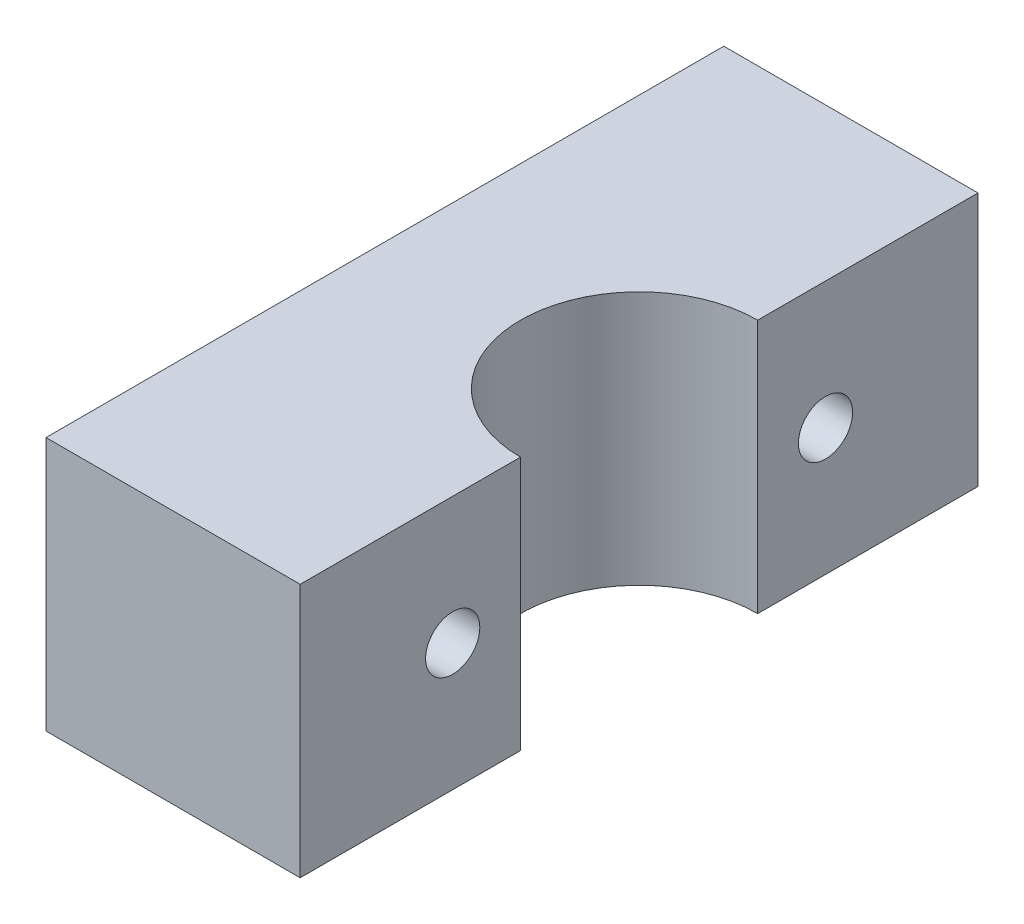
from build123d import *

# Parameters (mm, degrees)
BOSS_EXTRUDE1_DEPTH = 15
CUT_EXTRUDE2_REACH  = 17
SKETCH4_R           = 1.6


with BuildPart() as part:
    # Sketch1 → Boss-Extrude1 (new body)
    with BuildSketch(Plane(origin=(0, 0, 0), x_dir=(1, 0, 0), z_dir=(0, 1, 0))):
        with BuildLine():
            Line((7.5, 20), (7.5, 7))
            ThreePointArc((7.5, 7), (0.5, 0), (7.5, -7))
            Line((7.5, -7), (7.5, -20))
            Line((7.5, -20), (-7.5, -20))
            Line((-7.5, -20), (-7.5, 20))
            Line((-7.5, 20), (7.5, 20))
        make_face()
    extrude(amount=BOSS_EXTRUDE1_DEPTH)

    # Sketch4 → Cut-Extrude2 (cut, up to next)
    with BuildSketch(Plane(origin=(7.5, 0, 0), x_dir=(0, 0, -1), z_dir=(1, 0, 0)), mode=Mode.PRIVATE) as cut_extrude2_sk1:
        with Locations((11, 7.5)):
            Circle(SKETCH4_R)
    cut_extrude2_tool1 = extrude(cut_extrude2_sk1.sketch, amount=-CUT_EXTRUDE2_REACH, mode=Mode.PRIVATE) & part.part
    add(cut_extrude2_tool1.solids().sort_by_distance((7.5, 7.5, -11))[0], mode=Mode.SUBTRACT)
    # Sketch4 → Cut-Extrude2 (cut, up to next)
    with BuildSketch(Plane(origin=(7.5, 0, 0), x_dir=(0, 0, -1), z_dir=(1, 0, 0)), mode=Mode.PRIVATE) as cut_extrude2_sk2:
        with Locations((-11, 7.5)):
            Circle(SKETCH4_R)
    cut_extrude2_tool2 = extrude(cut_extrude2_sk2.sketch, amount=-CUT_EXTRUDE2_REACH, mode=Mode.PRIVATE) & part.part
    add(cut_extrude2_tool2.solids().sort_by_distance((7.5, 7.5, 11))[0], mode=Mode.SUBTRACT)


solid = part.part
